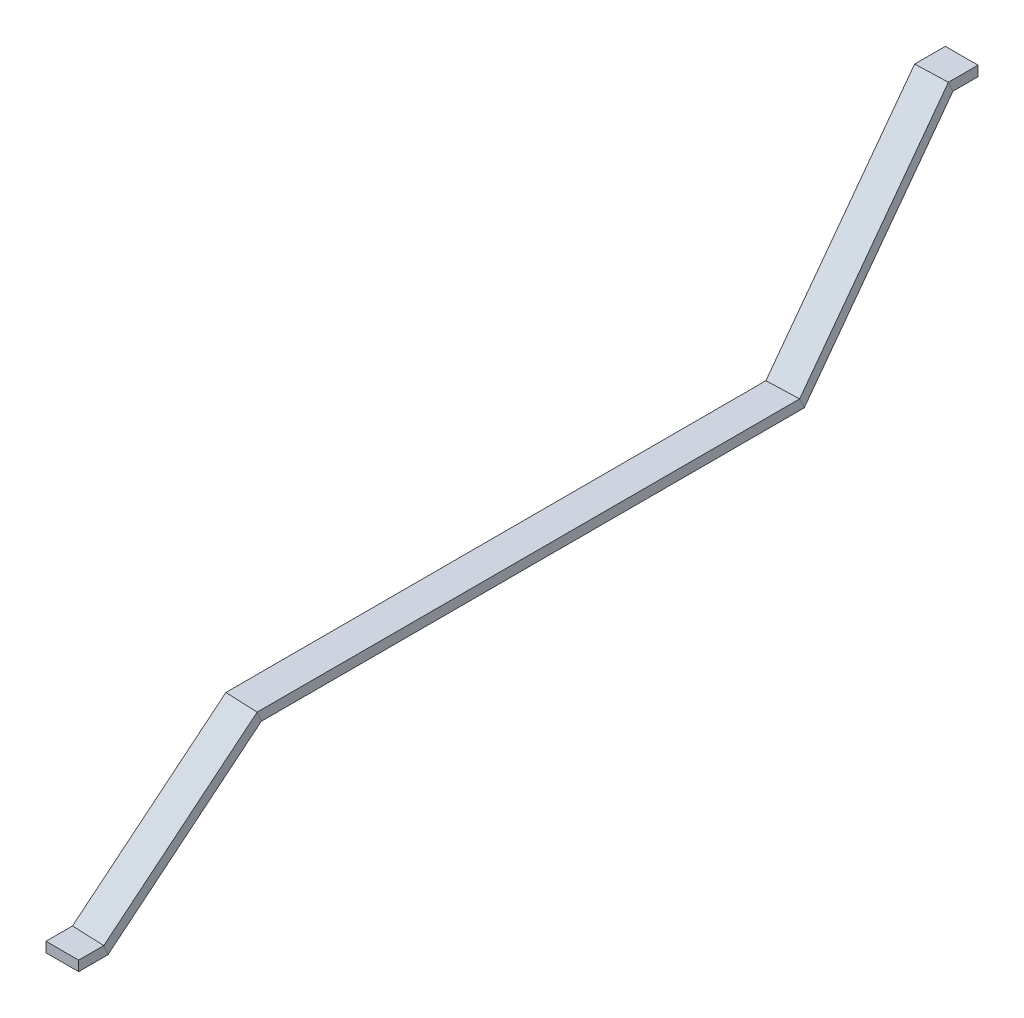
from build123d import *

# Parameters (mm, degrees)
SKETCH1_W = 70.25
SKETCH1_H = 21.6


with BuildPart() as part:
    # Sweep1: sweep along a curve in space
    with BuildLine() as sweep1_path:
        Line((-30, 400, -350), (-30, 400, -410))
        Line((0, 0, 0), (-30, 400, -350))
        Line((0, 0, 1165), (0, 0, 0))
        Line((-30, -300, 1465), (0, 0, 1165))
        Line((-30, -300, 1465), (-30, -300, 1525))
    # Sketch1 → Sweep1 (sweep)
    with BuildSketch(Plane(origin=(-30, 400, -410), x_dir=(1, 0, 0), z_dir=(0, 0, 1))):
        Rectangle(SKETCH1_W, SKETCH1_H)
    sweep(path=sweep1_path.line, transition=Transition.RIGHT)


solid = part.part
